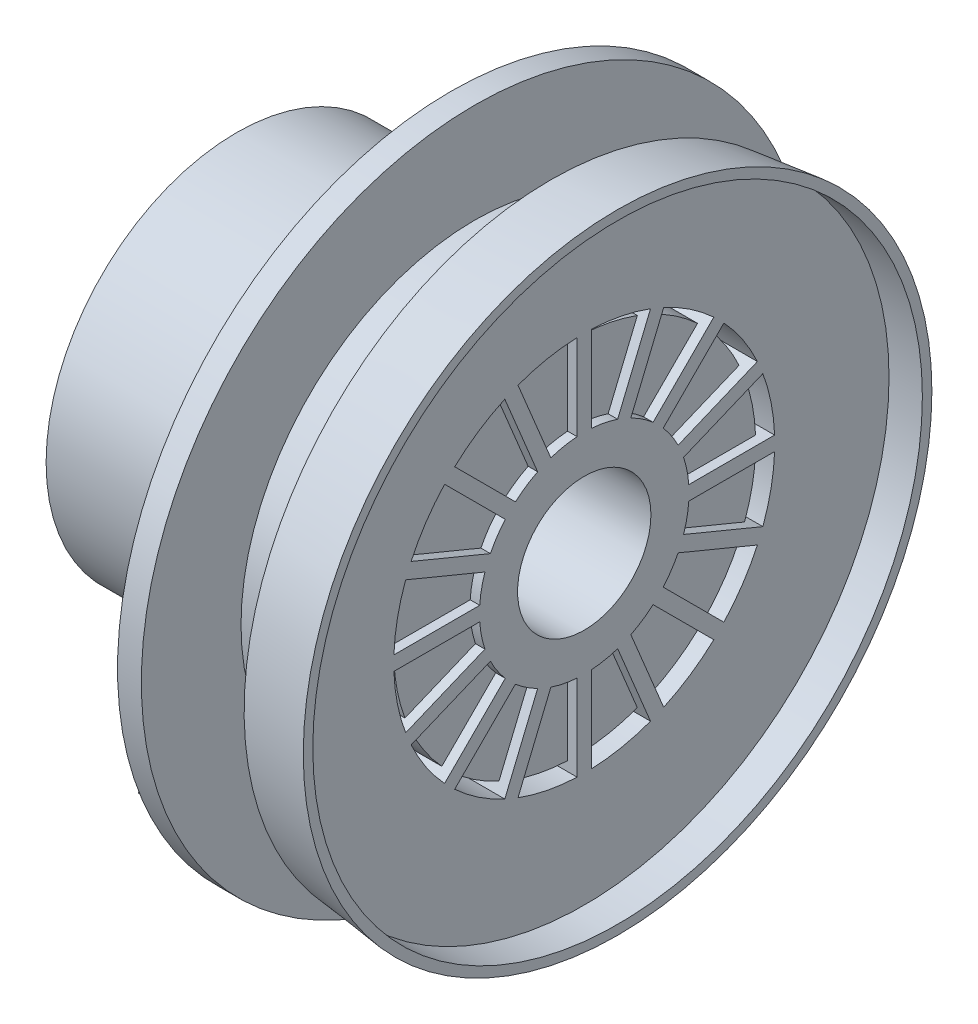
from build123d import *

# Parameters (mm, degrees)
BOSS_EXTRUDE1_DEPTH = 3
CUT_EXTRUDE1_DEPTH  = 10
CIRPATTERN1_COUNT   = 6
BOSS_EXTRUDE2_DEPTH = 10
SKETCH6_R           = 32
CUT_EXTRUDE2_DEPTH  = 3.5
SKETCH7_R           = 20
SKETCH7_R_2         = 11
CUT_EXTRUDE4_DEPTH  = 5.5
BOSS_EXTRUDE3_DEPTH = 5.5
CIRPATTERN2_COUNT   = 16
SKETCH10_R          = 19
BOSS_EXTRUDE4_DEPTH = 4.5
SKETCH11_R          = 18
CUT_EXTRUDE5_DEPTH  = 25.5
SKETCH12_R          = 8
SKETCH12_R_2        = 7
BOSS_EXTRUDE5_DEPTH = 5
SKETCH13_R          = 7
CUT_EXTRUDE6_DEPTH  = 23
SKETCH14_R          = 2
CUT_EXTRUDE9_DEPTH  = 6


with BuildPart() as part:
    # Sketch2 → Revolve2 (revolve)
    with BuildSketch(Plane.XY):
        Polygon((0, 0), (0, 33), (-7, 32.210806874), (-7, 24.5371762), (-15, 24.5371762), (-15, 35), (-17.5, 35), (-17.5, 20), (-40, 20), (-40, 0), align=None)
    revolve(axis=Axis((0, 0, 0), (-1, 0, 0)))

    # Sketch3 → Boss-Extrude1 (add)
    with BuildSketch(Plane.ZY.offset(17.5)):
        with BuildLine():
            Line((-1.119688757, 19.96863283), (-1.119688757, 31.952311667))
            Line((-1.119688757, 31.952311667), (1.380311243, 31.952311667))
            Line((1.380311243, 31.952311667), (1.380311243, 19.952311667))
            ThreePointArc((1.380311243, 19.952311667), (0.130566516, 19.999573805), (-1.119688757, 19.96863283))
        make_face()
    boss_extrude1 = extrude(amount=BOSS_EXTRUDE1_DEPTH)

    # Sketch4 → Cut-Extrude1 (cut)
    with BuildSketch(Plane.XY.offset(1.380311243)):
        Polygon((-20.5, 19.952311667), (-17.5, 31.952311667), (-20.5, 31.952311667), align=None)
    cut_extrude1 = extrude(amount=-CUT_EXTRUDE1_DEPTH, mode=Mode.SUBTRACT)

    # CirPattern1: Boss-Extrude1, Cut-Extrude1 ×6 about axis
    cirpattern1_axis = Axis((0, 0, 0), (1, 0, 0))
    for i in range(1, CIRPATTERN1_COUNT):
        add(boss_extrude1.rotate(cirpattern1_axis, i * 360 / CIRPATTERN1_COUNT))
        add(cut_extrude1.rotate(cirpattern1_axis, i * 360 / CIRPATTERN1_COUNT), mode=Mode.SUBTRACT)

    # Sketch5 → Boss-Extrude2 (add)
    with BuildSketch(Plane.ZY.offset(17.5)):
        with BuildLine():
            Line((0.341434911, -18.344937093), (15.591504627, -9.672552828))
            Line((15.591504627, -9.672552828), (22.828663164, -22.398830732))
            ThreePointArc((22.828663164, -22.398830732), (15.809898035, -27.801125951), (7.578593448, -31.071214997))
            Line((7.578593448, -31.071214997), (0.341434911, -18.344937093))
        make_face()
        with BuildLine():
            Line((2.659566405, -18.98232738), (14.95411434, -11.990684322))
            Line((14.95411434, -11.990684322), (20.702890868, -22.099697042))
            ThreePointArc((20.702890868, -22.099697042), (14.969527432, -26.323365061), (8.408342933, -29.091340099))
            Line((8.408342933, -29.091340099), (2.659566405, -18.98232738))
        make_face(mode=Mode.SUBTRACT)
    extrude(amount=BOSS_EXTRUDE2_DEPTH)

    # Sketch6 → Cut-Extrude2 (cut)
    with BuildSketch(Plane(origin=(0, 0, 0), x_dir=(0, 0, -1), z_dir=(1, 0, 0))):
        Circle(SKETCH6_R)
    extrude(amount=-CUT_EXTRUDE2_DEPTH, mode=Mode.SUBTRACT)

    # Sketch7 → Cut-Extrude4 (cut)
    with BuildSketch(Plane(origin=(-3.5, 0, 0), x_dir=(0, 0, -1), z_dir=(1, 0, 0))):
        Circle(SKETCH7_R)
        Circle(SKETCH7_R_2, mode=Mode.SUBTRACT)
    extrude(amount=-CUT_EXTRUDE4_DEPTH, mode=Mode.SUBTRACT)

    # Sketch9 → Boss-Extrude3 (add)
    with BuildSketch(Plane(origin=(-9, 0, 0), x_dir=(0, 0, -1), z_dir=(1, 0, 0))):
        with BuildLine():
            Line((0.75, 10.60425024), (0.75, 20.365350298))
            ThreePointArc((0.75, 20.365350298), (0, 20.37915584), (-0.75, 20.365350298))
            Line((-0.75, 20.365350298), (-0.75, 10.60425024))
            ThreePointArc((-0.75, 10.60425024), (0, 10.630739539), (0.75, 10.60425024))
        make_face()
    boss_extrude3 = extrude(amount=BOSS_EXTRUDE3_DEPTH)

    # CirPattern2: Boss-Extrude3 ×16 about axis
    cirpattern2_axis = Axis((0, 0, 0), (1, 0, 0))
    for i in range(1, CIRPATTERN2_COUNT):
        add(boss_extrude3.rotate(cirpattern2_axis, i * 360 / CIRPATTERN2_COUNT))

    # Sketch10 → Boss-Extrude4 (add)
    with BuildSketch(Plane(origin=(-9, 0, 0), x_dir=(0, 0, -1), z_dir=(1, 0, 0))):
        Circle(SKETCH10_R)
    extrude(amount=BOSS_EXTRUDE4_DEPTH)

    # Sketch11 → Cut-Extrude5 (cut)
    with BuildSketch(Plane.ZY.offset(40)):
        Circle(SKETCH11_R)
    extrude(amount=-CUT_EXTRUDE5_DEPTH, mode=Mode.SUBTRACT)

    # Sketch12 → Boss-Extrude5 (add)
    with BuildSketch(Plane.ZY.offset(14.5)):
        Circle(SKETCH12_R)
        Circle(SKETCH12_R_2, mode=Mode.SUBTRACT)
    extrude(amount=BOSS_EXTRUDE5_DEPTH)

    # Sketch13 → Cut-Extrude6 (cut)
    with BuildSketch(Plane.ZY.offset(14.5)):
        Circle(SKETCH13_R)
    extrude(amount=-CUT_EXTRUDE6_DEPTH, mode=Mode.SUBTRACT)

    # Sketch14 → Cut-Extrude9 (cut)
    with BuildSketch(Plane(origin=(-15, 0, 0), x_dir=(0, 0, -1), z_dir=(1, 0, 0))):
        with Locations((-13.549564178, -23.82641175)):
            Circle(SKETCH14_R)
    extrude(amount=-CUT_EXTRUDE9_DEPTH, mode=Mode.SUBTRACT)


solid = part.part
